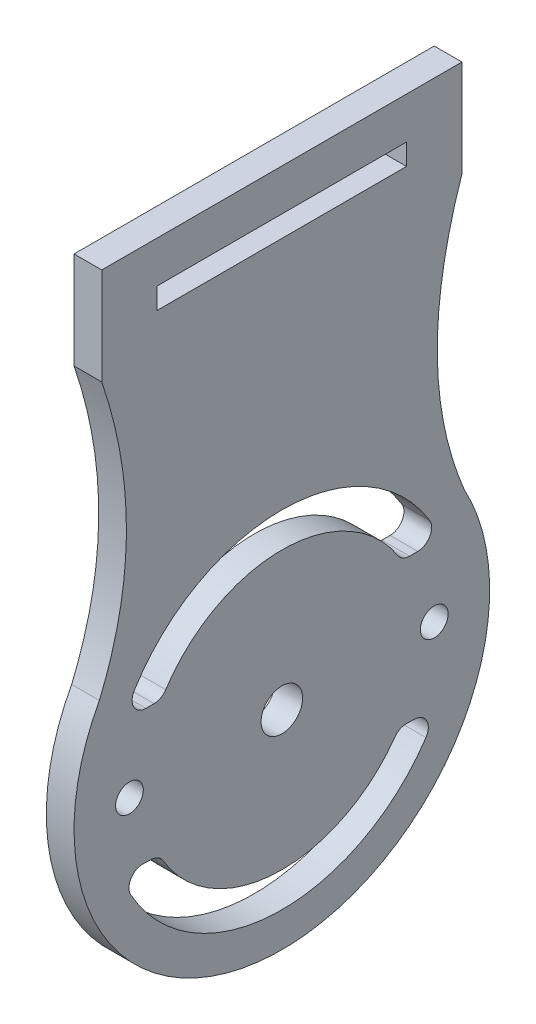
from build123d import *

# Parameters (mm, degrees)
RESSALTO_EXTRUS_O1_DEPTH = 2
ESBO_O2_R                = 1.5
ESBO_O2_R_2              = 1
ESBO_O2_W                = 18
ESBO_O2_H                = 1.527880785
CORTE_EXTRUS_O1_DEPTH    = 3.0000001


with BuildPart() as part:
    # Esboço1 → Ressalto-extrusão1 (new body)
    with BuildSketch(Plane(origin=(0, 0, 0), x_dir=(0, 0, -1), z_dir=(1, 0, 0))):
        with BuildLine():
            Line((-13, 34), (0, 34))
            Line((0, 34), (0, -15))
            ThreePointArc((0, -15), (-12.895532653, -7.661934325), (-13.173963237, 7.172634986))
            add(Edge.make_bspline(
                [(-13, 27), (-9.354199414, 16.239964162), (-13.173963237, 7.172634986)],
                knots=[0, 0, 0, 0.912495845, 0.912495845, 0.912495845], degree=2))
            Line((-13, 27), (-13, 34))
        make_face()
    ressalto_extrus_o1 = extrude(amount=RESSALTO_EXTRUS_O1_DEPTH)

    # Espelhar1: Ressalto-extrusão1 across plane
    add(ressalto_extrus_o1.mirror(Plane(origin=(2, 34, 0), x_dir=(1, 0, 0), z_dir=(0, 0, 1))))

    # Esboço2 → Corte-extrusão1 (cut, through all)
    with BuildSketch(Plane(origin=(2, 0, 0), x_dir=(0, 0, -1), z_dir=(1, 0, 0))):
        Circle(ESBO_O2_R)
        with Locations((11, 0)):
            Circle(ESBO_O2_R_2)
        with Locations((-11, 0)):
            Circle(ESBO_O2_R_2)
        with Locations((0, 30.236059608)):
            Rectangle(ESBO_O2_W, ESBO_O2_H)
        with BuildLine():
            Line((-9.810708435, 5), (-9.219544457, 5))
            ThreePointArc((-9.219544457, 5), (-8.742813163, 5.120950927), (-8.381404052, 5.454545455))
            ThreePointArc((-8.381404052, 5.454545455), (0, 10), (8.381404052, 5.454545455))
            ThreePointArc((8.381404052, 5.454545455), (8.742813163, 5.120950927), (9.219544457, 5))
            Line((9.219544457, 5), (9.810708435, 5))
            ThreePointArc((9.810708435, 5), (10.682986811, 5.510990353), (10.663813516, 6.52173913))
            ThreePointArc((10.663813516, 6.52173913), (0, 12.5), (-10.663813516, 6.52173913))
            ThreePointArc((-10.663813516, 6.52173913), (-10.682986811, 5.510990353), (-9.810708435, 5))
        make_face()
        with BuildLine():
            Line((-9.996736389, -4.616845413), (-9.40601466, -4.639707772))
            ThreePointArc((-9.40601466, -4.639707772), (-8.934317599, -4.779005068), (-8.586080114, -5.126326976))
            ThreePointArc((-8.586080114, -5.126326976), (-0.386734657, -9.992519017), (8.164187762, -5.77460286))
            ThreePointArc((8.164187762, -5.77460286), (8.538227759, -5.455234837), (9.019280003, -5.352811245))
            Line((9.019280003, -5.352811245), (9.610001733, -5.375673604))
            ThreePointArc((9.610001733, -5.375673604), (10.461865791, -5.920015714), (10.403617681, -6.929266854))
            ThreePointArc((10.403617681, -6.929266854), (-0.483418321, -12.490648771), (-10.90805419, -6.104453603))
            ThreePointArc((-10.90805419, -6.104453603), (-10.888123983, -5.093719467), (-9.996736389, -4.616845413))
        make_face()
    extrude(amount=-CORTE_EXTRUS_O1_DEPTH, mode=Mode.SUBTRACT)


solid = part.part
